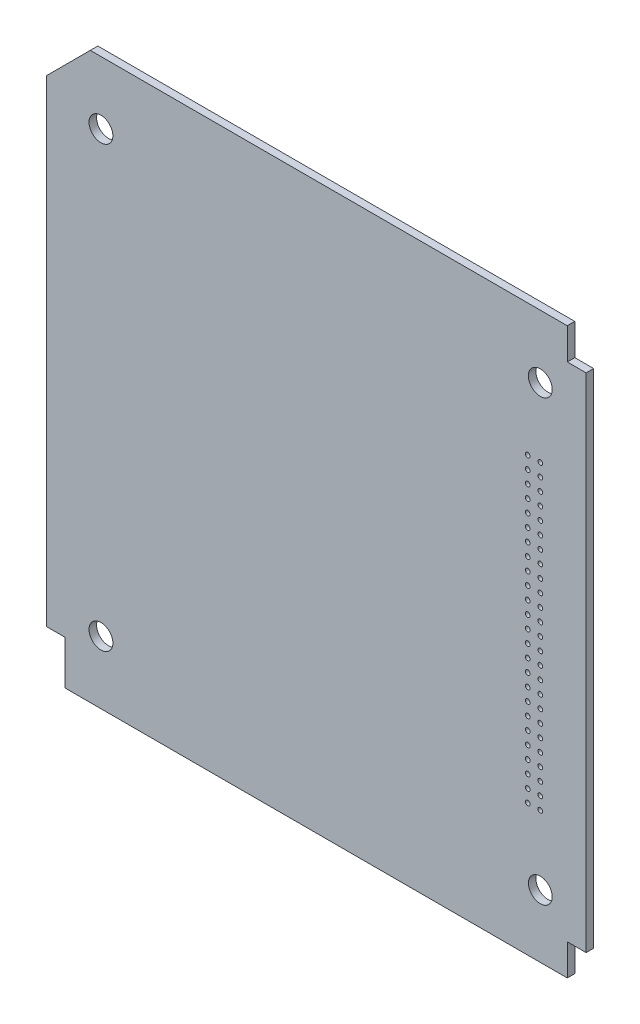
from build123d import *

# Parameters (mm, degrees)
SKETCH1_R           = 1.9
SKETCH1_R_2         = 0.375
SKETCH1_R_3         = 0.383755901
SKETCH1_R_4         = 0.384163196
SKETCH1_R_5         = 0.380771211
SKETCH1_R_6         = 0.377379225
SKETCH1_R_7         = 0.380832793
BOSS_EXTRUDE1_DEPTH = 1.2
SKETCH_1_W          = 3
SKETCH_1_H          = 7
CUT_EXTRUDE_1_DEPTH = 10


with BuildPart() as part:
    # Sketch1 → Boss-Extrude1 (new body)
    with BuildSketch(Plane.XY):
        Polygon((-3, 0), (-86, 0), (-86, -90), (-3, -90), (-3, -85), (0, -85), (0, -5), (-3, -5), align=None)
        with Locations((-7.3, -10)):
            Circle(SKETCH1_R, mode=Mode.SUBTRACT)
        with Locations((-77.3, -10)):
            Circle(SKETCH1_R, mode=Mode.SUBTRACT)
        with Locations((-77.3, -80)):
            Circle(SKETCH1_R, mode=Mode.SUBTRACT)
        with Locations((-7.3, -80)):
            Circle(SKETCH1_R, mode=Mode.SUBTRACT)
        with Locations((-9.3, -69)):
            Circle(SKETCH1_R_2, mode=Mode.SUBTRACT)
        with Locations((-7.3, -69)):
            Circle(SKETCH1_R_2, mode=Mode.SUBTRACT)
        with Locations((-7.3, -67)):
            Circle(SKETCH1_R_2, mode=Mode.SUBTRACT)
        with Locations((-9.3, -67)):
            Circle(SKETCH1_R_2, mode=Mode.SUBTRACT)
        with Locations((-9.3, -65)):
            Circle(SKETCH1_R_2, mode=Mode.SUBTRACT)
        with Locations((-7.3, -65)):
            Circle(SKETCH1_R_2, mode=Mode.SUBTRACT)
        with Locations((-7.3, -63)):
            Circle(SKETCH1_R_2, mode=Mode.SUBTRACT)
        with Locations((-9.3, -63)):
            Circle(SKETCH1_R_3, mode=Mode.SUBTRACT)
        with Locations((-9.3, -61)):
            Circle(SKETCH1_R_2, mode=Mode.SUBTRACT)
        with Locations((-7.3, -61)):
            Circle(SKETCH1_R_2, mode=Mode.SUBTRACT)
        with Locations((-7.3, -59)):
            Circle(SKETCH1_R_2, mode=Mode.SUBTRACT)
        with Locations((-9.3, -59)):
            Circle(SKETCH1_R_2, mode=Mode.SUBTRACT)
        with Locations((-7.3, -57)):
            Circle(SKETCH1_R_2, mode=Mode.SUBTRACT)
        with Locations((-9.3, -57)):
            Circle(SKETCH1_R_2, mode=Mode.SUBTRACT)
        with Locations((-9.3, -55)):
            Circle(SKETCH1_R_2, mode=Mode.SUBTRACT)
        with Locations((-7.3, -55)):
            Circle(SKETCH1_R_2, mode=Mode.SUBTRACT)
        with Locations((-7.3, -53)):
            Circle(SKETCH1_R_2, mode=Mode.SUBTRACT)
        with Locations((-9.3, -53)):
            Circle(SKETCH1_R_2, mode=Mode.SUBTRACT)
        with Locations((-9.3, -51)):
            Circle(SKETCH1_R_2, mode=Mode.SUBTRACT)
        with Locations((-7.3, -51)):
            Circle(SKETCH1_R_2, mode=Mode.SUBTRACT)
        with Locations((-7.3, -49)):
            Circle(SKETCH1_R_2, mode=Mode.SUBTRACT)
        with Locations((-9.3, -49)):
            Circle(SKETCH1_R_2, mode=Mode.SUBTRACT)
        with Locations((-9.3, -47)):
            Circle(SKETCH1_R_2, mode=Mode.SUBTRACT)
        with Locations((-7.3, -47)):
            Circle(SKETCH1_R_2, mode=Mode.SUBTRACT)
        with Locations((-7.3, -45)):
            Circle(SKETCH1_R_2, mode=Mode.SUBTRACT)
        with Locations((-9.3, -45)):
            Circle(SKETCH1_R_4, mode=Mode.SUBTRACT)
        with Locations((-9.3, -43)):
            Circle(SKETCH1_R_2, mode=Mode.SUBTRACT)
        with Locations((-7.3, -43)):
            Circle(SKETCH1_R_5, mode=Mode.SUBTRACT)
        with Locations((-7.3, -41)):
            Circle(SKETCH1_R_6, mode=Mode.SUBTRACT)
        with Locations((-9.3, -41)):
            Circle(SKETCH1_R_6, mode=Mode.SUBTRACT)
        with Locations((-9.3, -39)):
            Circle(SKETCH1_R_2, mode=Mode.SUBTRACT)
        with Locations((-7.3, -39)):
            Circle(SKETCH1_R_2, mode=Mode.SUBTRACT)
        with Locations((-7.3, -37)):
            Circle(SKETCH1_R_2, mode=Mode.SUBTRACT)
        with Locations((-9.3, -37)):
            Circle(SKETCH1_R_7, mode=Mode.SUBTRACT)
        with Locations((-7.3, -35)):
            Circle(SKETCH1_R_2, mode=Mode.SUBTRACT)
        with Locations((-9.3, -35)):
            Circle(SKETCH1_R_2, mode=Mode.SUBTRACT)
        with Locations((-9.3, -33)):
            Circle(SKETCH1_R_2, mode=Mode.SUBTRACT)
        with Locations((-7.3, -33)):
            Circle(SKETCH1_R_2, mode=Mode.SUBTRACT)
        with Locations((-7.3, -31)):
            Circle(SKETCH1_R_2, mode=Mode.SUBTRACT)
        with Locations((-9.3, -31)):
            Circle(SKETCH1_R_2, mode=Mode.SUBTRACT)
        with Locations((-7.3, -29)):
            Circle(SKETCH1_R_2, mode=Mode.SUBTRACT)
        with Locations((-9.3, -29)):
            Circle(SKETCH1_R_2, mode=Mode.SUBTRACT)
        with Locations((-9.3, -27)):
            Circle(SKETCH1_R_2, mode=Mode.SUBTRACT)
        with Locations((-7.3, -27)):
            Circle(SKETCH1_R_2, mode=Mode.SUBTRACT)
        with Locations((-7.3, -25)):
            Circle(SKETCH1_R_2, mode=Mode.SUBTRACT)
        with Locations((-9.3, -25)):
            Circle(SKETCH1_R_2, mode=Mode.SUBTRACT)
        with Locations((-7.3, -23)):
            Circle(SKETCH1_R_2, mode=Mode.SUBTRACT)
        with Locations((-9.3, -23)):
            Circle(SKETCH1_R_2, mode=Mode.SUBTRACT)
        with Locations((-9.3, -21)):
            Circle(SKETCH1_R_2, mode=Mode.SUBTRACT)
        with Locations((-7.3, -21)):
            Circle(SKETCH1_R_2, mode=Mode.SUBTRACT)
    extrude(amount=BOSS_EXTRUDE1_DEPTH)

    # ｽｹｯﾁ1 → ｶｯﾄ - 押し出し1 (cut)
    with BuildSketch(Plane.XY.offset(1.2)):
        with Locations((-84.5, -86.5)):
            Rectangle(SKETCH_1_W, SKETCH_1_H)
        Polygon((-86, -7), (-86, 0), (-79, 0), align=None)
    extrude(amount=-CUT_EXTRUDE_1_DEPTH, mode=Mode.SUBTRACT)


solid = part.part
